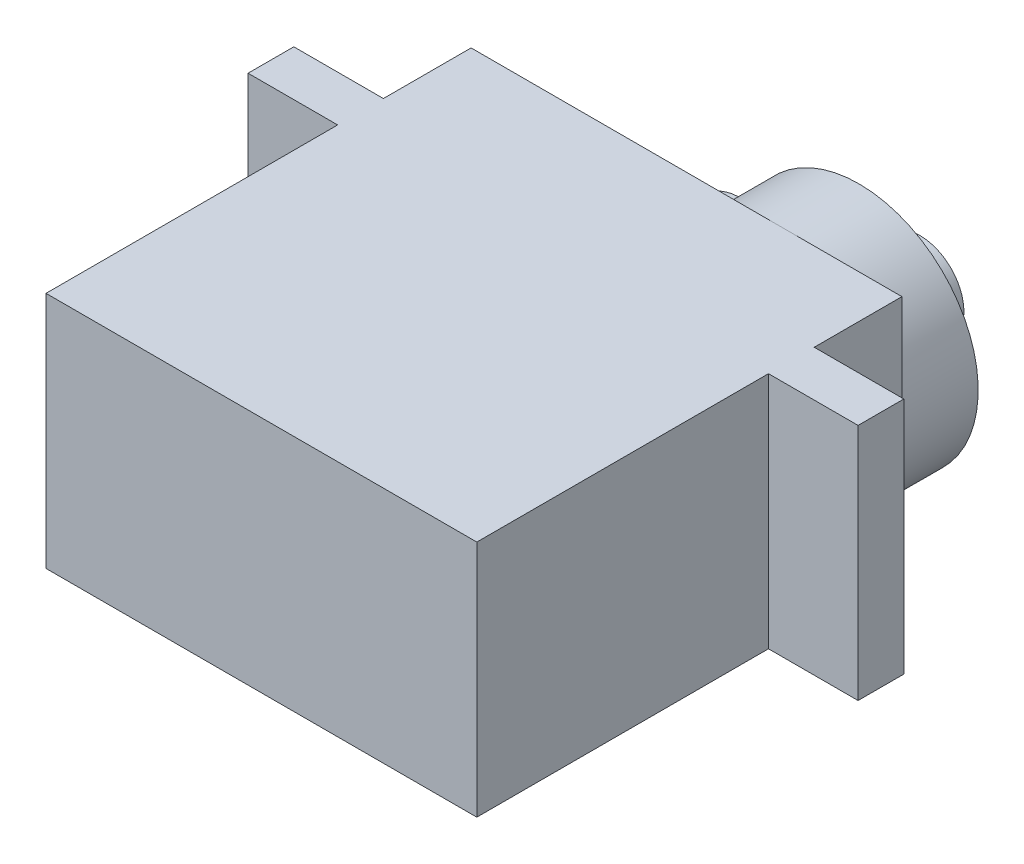
from build123d import *

# Parameters (mm, degrees)
BOSS_EXTRUDE1_DEPTH = 12.5
BOSS_EXTRUDE2_DEPTH = 4
SKETCH3_R           = 2.3
BOSS_EXTRUDE3_DEPTH = 3.2


with BuildPart() as part:
    # Sketch1 → Boss-Extrude1 (new body)
    with BuildSketch(Plane(origin=(0, 0, 0), x_dir=(1, 0, 0), z_dir=(0, 1, 0))):
        Polygon((0, 17.7), (0, 22.3), (22.6, 22.3), (22.6, 17.7), (27.3, 17.7), (27.3, 15.3), (22.6, 15.3), (22.6, 0), (0, 0), (0, 15.3), (-4.7, 15.3), (-4.7, 17.7), align=None)
    extrude(amount=BOSS_EXTRUDE1_DEPTH)

    # Sketch2 → Boss-Extrude2 (add)
    with BuildSketch(Plane(origin=(0, 0, -22.3), x_dir=(-1, 0, 0), z_dir=(0, 0, -1))):
        with BuildLine():
            ThreePointArc((-10.6, 8.699489743), (-22.6, 6.25), (-10.6, 3.800510257))
            ThreePointArc((-10.6, 3.800510257), (-7.6, 6.25), (-10.6, 8.699489743))
        make_face()
    extrude(amount=BOSS_EXTRUDE2_DEPTH)

    # Sketch3 → Boss-Extrude3 (add)
    with BuildSketch(Plane(origin=(0, 0, -26.3), x_dir=(-1, 0, 0), z_dir=(0, 0, -1))):
        with Locations((-16.35, 6.25)):
            Circle(SKETCH3_R)
    extrude(amount=BOSS_EXTRUDE3_DEPTH)


solid = part.part
